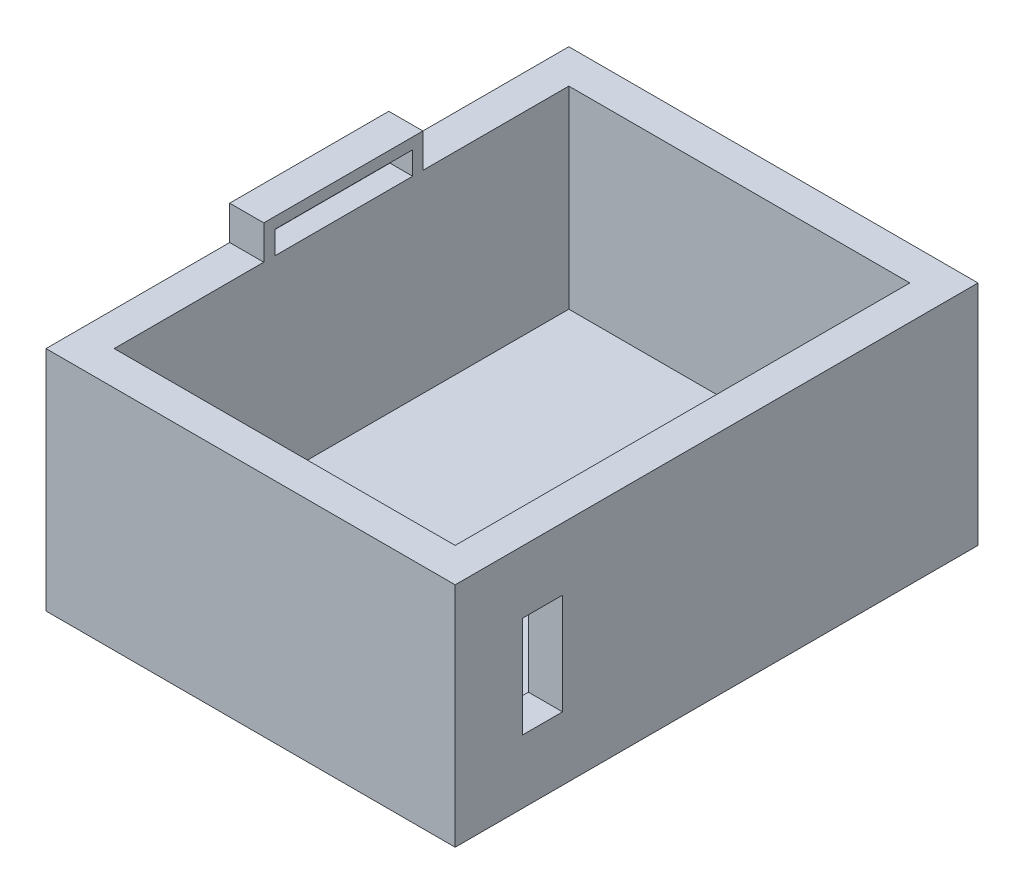
from build123d import *

# Parameters (mm, degrees)
SKETCH1_W           = 180
SKETCH1_H           = 230
SKETCH1_W_2         = 150
SKETCH1_H_2         = 200
BOSS_EXTRUDE1_DEPTH = 100
SKETCH2_W           = 180
SKETCH2_H           = 230
BOSS_EXTRUDE2_DEPTH = 15
SKETCH3_W           = 15
SKETCH3_H           = 70
BOSS_EXTRUDE3_DEPTH = 15
SKETCH4_W           = 60.52486508
SKETCH4_H           = 10.102082312
CUT_EXTRUDE1_DEPTH  = 10
SKETCH5_W           = 17.690019853
SKETCH5_H           = 44.485196982
CUT_EXTRUDE2_DEPTH  = 20


with BuildPart() as part:
    # Sketch1 → Boss-Extrude1 (new body)
    with BuildSketch(Plane(origin=(0, 0, 0), x_dir=(1, 0, 0), z_dir=(0, 1, 0))):
        Rectangle(SKETCH1_W, SKETCH1_H)
        Rectangle(SKETCH1_W_2, SKETCH1_H_2, mode=Mode.SUBTRACT)
    extrude(amount=BOSS_EXTRUDE1_DEPTH)

    # Sketch2 → Boss-Extrude2 (add)
    with BuildSketch(Plane.XZ):
        Rectangle(SKETCH2_W, SKETCH2_H)
    extrude(amount=-BOSS_EXTRUDE2_DEPTH)

    # Sketch3 → Boss-Extrude3 (add)
    with BuildSketch(Plane(origin=(0, 100, 0), x_dir=(1, 0, 0), z_dir=(0, 1, 0))):
        with Locations((-82.5, 0.801504388)):
            Rectangle(SKETCH3_W, SKETCH3_H)
    extrude(amount=BOSS_EXTRUDE3_DEPTH)

    # Sketch4 → Cut-Extrude1 (cut)
    with BuildSketch(Plane(origin=(-75, 0, 0), x_dir=(0, 0, -1), z_dir=(1, 0, 0))):
        with Locations((1.039053478, 105.051041156)):
            Rectangle(SKETCH4_W, SKETCH4_H)
    extrude(amount=-CUT_EXTRUDE1_DEPTH, mode=Mode.SUBTRACT)

    # Sketch5 → Cut-Extrude2 (cut)
    with BuildSketch(Plane(origin=(90, 0, 0), x_dir=(0, 0, -1), z_dir=(1, 0, 0))):
        with Locations((-76.613394803, 50.215874178)):
            Rectangle(SKETCH5_W, SKETCH5_H)
    extrude(amount=-CUT_EXTRUDE2_DEPTH, mode=Mode.SUBTRACT)


solid = part.part
